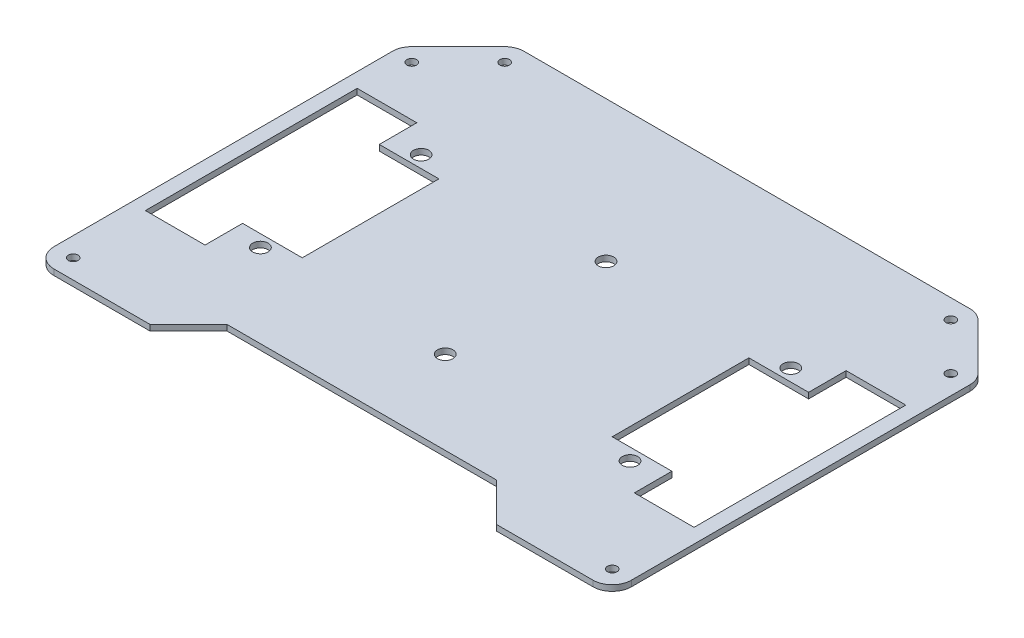
from build123d import *

# Parameters (mm, degrees)
ESQUISSE1_R      = 4
EXTRUSION1_DEPTH = 3
CONG_2_R         = 10
EXTRUSION2_REACH = 5
ESQUISSE3_R      = 2.5
EXTRUSION3_REACH = 5


with BuildPart() as part:
    # Esquisse1 → Extrusion1 (new body)
    with BuildSketch(Plane(origin=(0, 0, 0), x_dir=(1, 0, 0), z_dir=(0, 1, 0))):
        Polygon((-150, -105), (150, -105), (150, 0), (150, 85), (120, 115), (-120, 115), (-150, 85), (-150, 0), align=None)
        with Locations((0, 41.75)):
            Circle(ESQUISSE1_R, mode=Mode.SUBTRACT)
        with Locations((-96, 41.75)):
            Circle(ESQUISSE1_R, mode=Mode.SUBTRACT)
        with Locations((0, -41.75)):
            Circle(ESQUISSE1_R, mode=Mode.SUBTRACT)
        with Locations((-96, -41.75)):
            Circle(ESQUISSE1_R, mode=Mode.SUBTRACT)
        with Locations((96, -41.75)):
            Circle(ESQUISSE1_R, mode=Mode.SUBTRACT)
        with Locations((96, 41.75)):
            Circle(ESQUISSE1_R, mode=Mode.SUBTRACT)
        Polygon((-142.5, 55), (-142.5, -55), (-111.5, -55), (-111.5, -35.5), (-80.5, -35.5), (-80.5, 35.5), (-111.5, 35.5), (-111.5, 55), align=None, mode=Mode.SUBTRACT)
        Polygon((111.5, 55), (142.5, 55), (142.5, -55), (111.5, -55), (111.5, -35.5), (80.5, -35.5), (80.5, 35.5), (111.5, 35.5), align=None, mode=Mode.SUBTRACT)
    extrude(amount=EXTRUSION1_DEPTH)

    # Congé2
    cong_2_edges = [part.edges().sort_by_distance(p)[0] for p in [
        (150, 1.5, -85),
        (150, 1.5, 105),
        (-150, 1.5, 105),
        (-150, 1.5, -85),
        (-120, 1.5, -115),
        (120, 1.5, -115),
    ]]
    fillet(cong_2_edges, radius=CONG_2_R)

    # Esquisse3 → Extrusion2 (cut, up to next)
    with BuildSketch(Plane(origin=(0, 3, 0), x_dir=(1, 0, 0), z_dir=(0, 1, 0)), mode=Mode.PRIVATE) as extrusion2_sk1:
        with Locations((-140, -95)):
            Circle(ESQUISSE3_R)
    extrusion2_tool1 = extrude(extrusion2_sk1.sketch, amount=-EXTRUSION2_REACH, mode=Mode.PRIVATE) & part.part
    add(extrusion2_tool1.solids().sort_by_distance((-140, 3, 95))[0], mode=Mode.SUBTRACT)
    # Esquisse3 → Extrusion2 (cut, up to next)
    with BuildSketch(Plane(origin=(0, 3, 0), x_dir=(1, 0, 0), z_dir=(0, 1, 0)), mode=Mode.PRIVATE) as extrusion2_sk2:
        with Locations((-140, 80.857864376)):
            Circle(ESQUISSE3_R)
    extrusion2_tool2 = extrude(extrusion2_sk2.sketch, amount=-EXTRUSION2_REACH, mode=Mode.PRIVATE) & part.part
    add(extrusion2_tool2.solids().sort_by_distance((-140, 3, -80.857864))[0], mode=Mode.SUBTRACT)
    # Esquisse3 → Extrusion2 (cut, up to next)
    with BuildSketch(Plane(origin=(0, 3, 0), x_dir=(1, 0, 0), z_dir=(0, 1, 0)), mode=Mode.PRIVATE) as extrusion2_sk3:
        with Locations((-115.857864376, 105)):
            Circle(ESQUISSE3_R)
    extrusion2_tool3 = extrude(extrusion2_sk3.sketch, amount=-EXTRUSION2_REACH, mode=Mode.PRIVATE) & part.part
    add(extrusion2_tool3.solids().sort_by_distance((-115.857864, 3, -105))[0], mode=Mode.SUBTRACT)
    # Esquisse3 → Extrusion2 (cut, up to next)
    with BuildSketch(Plane(origin=(0, 3, 0), x_dir=(1, 0, 0), z_dir=(0, 1, 0)), mode=Mode.PRIVATE) as extrusion2_sk4:
        with Locations((140, -95)):
            Circle(ESQUISSE3_R)
    extrusion2_tool4 = extrude(extrusion2_sk4.sketch, amount=-EXTRUSION2_REACH, mode=Mode.PRIVATE) & part.part
    add(extrusion2_tool4.solids().sort_by_distance((140, 3, 95))[0], mode=Mode.SUBTRACT)
    # Esquisse3 → Extrusion2 (cut, up to next)
    with BuildSketch(Plane(origin=(0, 3, 0), x_dir=(1, 0, 0), z_dir=(0, 1, 0)), mode=Mode.PRIVATE) as extrusion2_sk5:
        with Locations((140, 80.857864376)):
            Circle(ESQUISSE3_R)
    extrusion2_tool5 = extrude(extrusion2_sk5.sketch, amount=-EXTRUSION2_REACH, mode=Mode.PRIVATE) & part.part
    add(extrusion2_tool5.solids().sort_by_distance((140, 3, -80.857864))[0], mode=Mode.SUBTRACT)
    # Esquisse3 → Extrusion2 (cut, up to next)
    with BuildSketch(Plane(origin=(0, 3, 0), x_dir=(1, 0, 0), z_dir=(0, 1, 0)), mode=Mode.PRIVATE) as extrusion2_sk6:
        with Locations((115.857864376, 105)):
            Circle(ESQUISSE3_R)
    extrusion2_tool6 = extrude(extrusion2_sk6.sketch, amount=-EXTRUSION2_REACH, mode=Mode.PRIVATE) & part.part
    add(extrusion2_tool6.solids().sort_by_distance((115.857864, 3, -105))[0], mode=Mode.SUBTRACT)

    # Esquisse4 → Extrusion3 (cut, up to next)
    with BuildSketch(Plane(origin=(0, 3, 0), x_dir=(1, 0, 0), z_dir=(0, 1, 0)), mode=Mode.PRIVATE) as extrusion3_sk1:
        Polygon((-90, -105), (-70, -85), (70, -85), (90, -105), align=None)
    extrusion3_tool1 = extrude(extrusion3_sk1.sketch, amount=-EXTRUSION3_REACH, mode=Mode.PRIVATE) & part.part
    add(extrusion3_tool1.solids().sort_by_distance((0, 3, 95.416667))[0], mode=Mode.SUBTRACT)


solid = part.part
